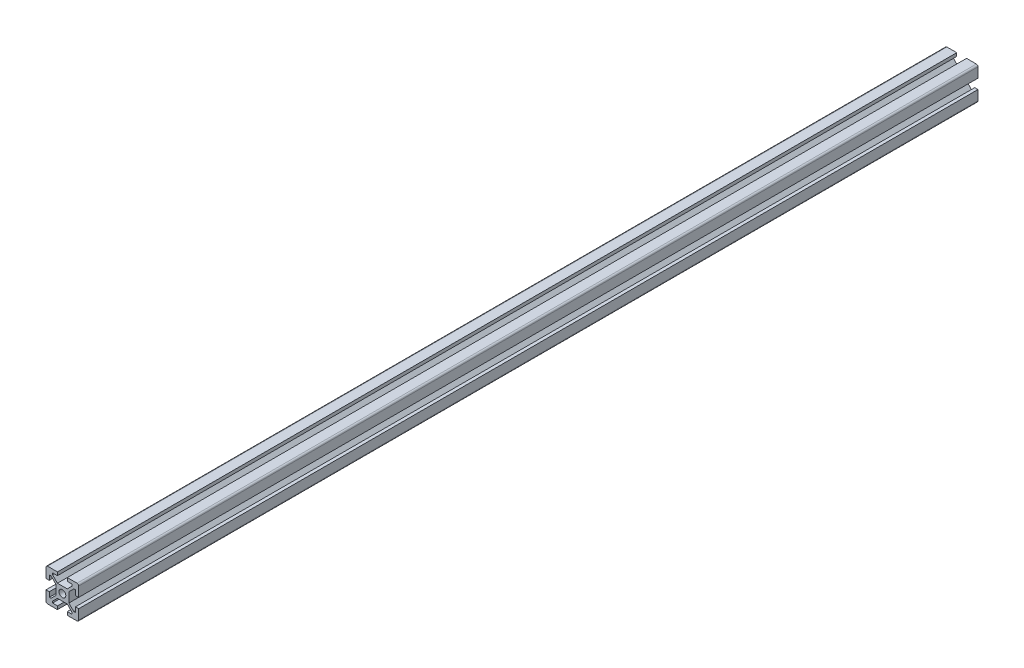
from build123d import *

# Parameters (mm, degrees)
SCHIZZO1_R                   = 2.1
ESTRUSIONE_ESTRUSIONE1_DEPTH = 550
RACCORDO1_R                  = 1


with BuildPart() as part:
    # Schizzo1 → Estrusione-Estrusione1 (new body)
    with BuildSketch(Plane.XY):
        Polygon((10, 3), (10, 10), (3, 10), (3, 8), (6, 8), (6, 7), (3, 4), (-3, 4), (-6, 7), (-6, 8), (-3, 8), (-3, 10), (-10, 10), (-10, 3), (-8, 3), (-8, 6), (-7, 6), (-4, 3), (-4, -3), (-7, -6), (-8, -6), (-8, -3), (-10, -3), (-10, -10), (-3, -10), (-3, -8), (-6, -8), (-6, -7), (-3, -4), (3, -4), (6, -7), (6, -8), (3, -8), (3, -10), (10, -10), (10, -3), (8, -3), (8, -6), (7, -6), (4, -3), (4, 3), (7, 6), (8, 6), (8, 3), align=None)
        Circle(SCHIZZO1_R, mode=Mode.SUBTRACT)
    extrude(amount=ESTRUSIONE_ESTRUSIONE1_DEPTH)

    # Raccordo1
    raccordo1_edges = [part.edges().sort_by_distance(p)[0] for p in [
        (-10, 10, 275),
        (10, 10, 275),
        (10, -10, 275),
        (-10, -10, 275),
    ]]
    fillet(raccordo1_edges, radius=RACCORDO1_R)


solid = part.part
